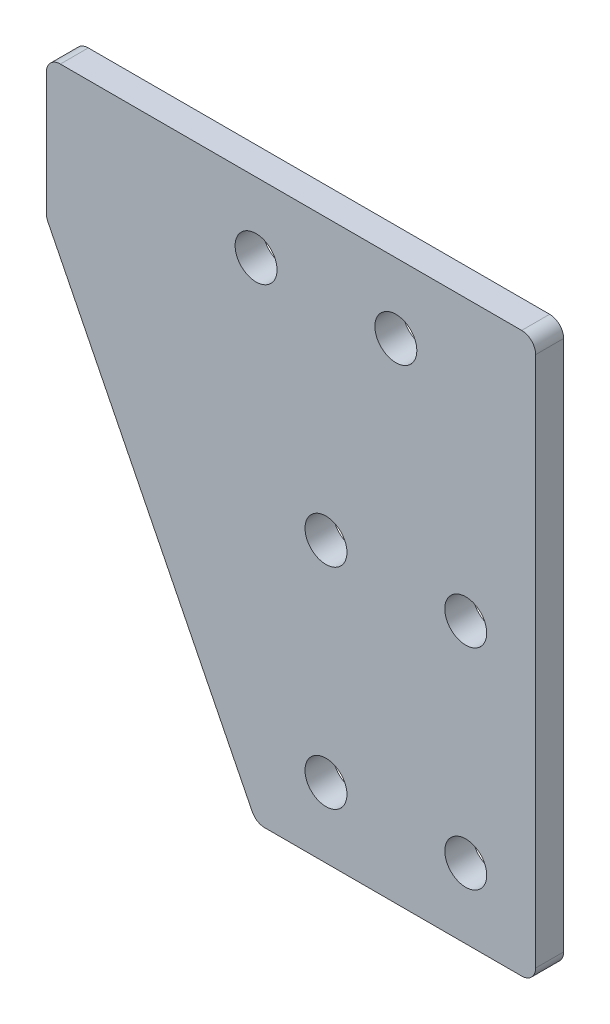
from build123d import *

# Parameters (mm, degrees)
SKETCH_1_R      = 1.5
EXTRUDE_1_DEPTH = 2
FILLET_1_R      = 1


with BuildPart() as part:
    # 草图1 → 凸台-拉伸1 (new body)
    with BuildSketch(Plane.XY):
        Polygon((-30, -5), (-30, 5), (5, 5), (5, -35), (-15, -35), align=None)
        with Locations((-15, 0)):
            Circle(SKETCH_1_R, mode=Mode.SUBTRACT)
        with Locations((-5, 0)):
            Circle(SKETCH_1_R, mode=Mode.SUBTRACT)
        with Locations((-10, -15)):
            Circle(SKETCH_1_R, mode=Mode.SUBTRACT)
        with Locations((-10, -30)):
            Circle(SKETCH_1_R, mode=Mode.SUBTRACT)
        with Locations((0, -30)):
            Circle(SKETCH_1_R, mode=Mode.SUBTRACT)
        with Locations((0, -15)):
            Circle(SKETCH_1_R, mode=Mode.SUBTRACT)
    extrude(amount=EXTRUDE_1_DEPTH)

    # 圆角1
    fillet_1_edges = [part.edges().sort_by_distance(p)[0] for p in [
        (-30, -5, 1),
        (-30, 5, 1),
        (5, 5, 1),
        (5, -35, 1),
        (-15, -35, 1),
    ]]
    fillet(fillet_1_edges, radius=FILLET_1_R)


solid = part.part
